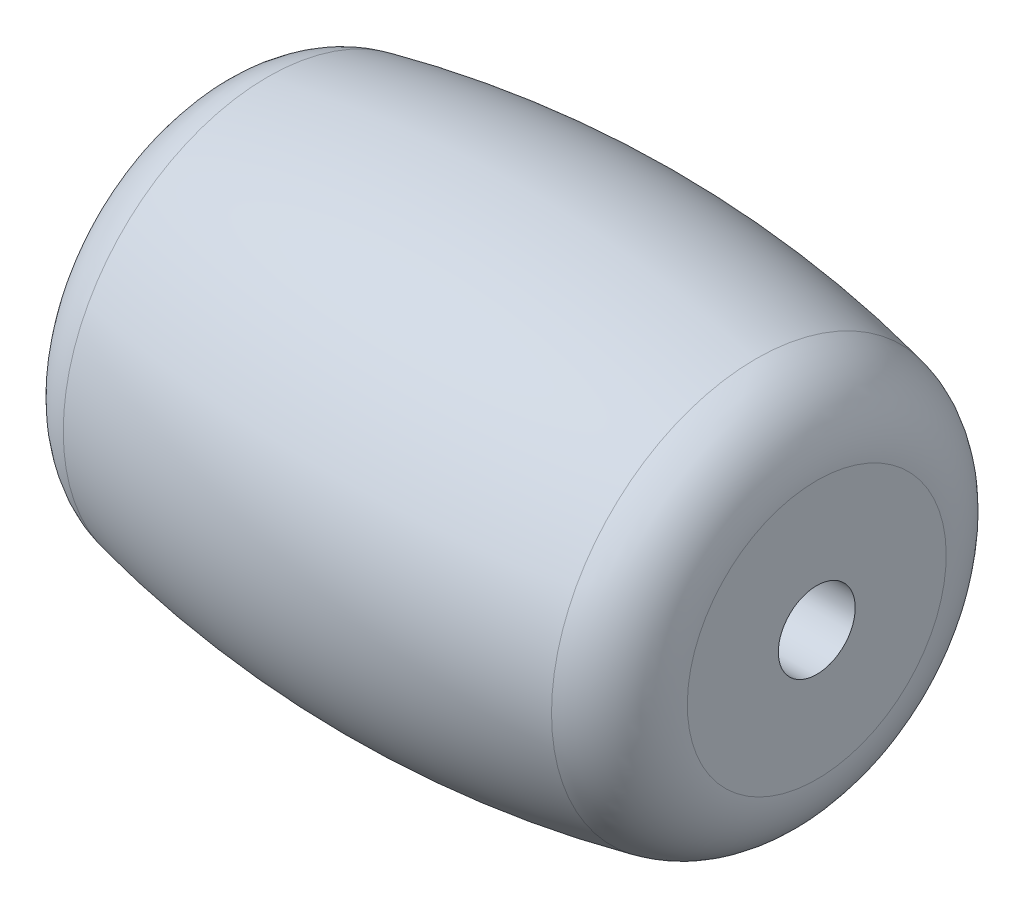
from build123d import *

# Parameters (mm, degrees)
RACCORDO1_R          = 2
RACCORDO2_R          = 2
FORO_0_2_0_2_1_D     = 2
FORO_0_2_0_2_1_DEPTH = 15.85


with BuildPart() as part:
    # Schizzo1 → Rivoluzione1 (revolve)
    with BuildSketch(Plane(origin=(0, 0, 0), x_dir=(-1, 0, 0), z_dir=(0, 0, -1))):
        with BuildLine():
            Line((-7.925, 4.934311379), (-7.925, 0))
            Line((-7.925, 0), (7.925, 0))
            Line((7.925, 0), (7.925, 4.934311379))
            ThreePointArc((7.925, 4.934311379), (0, 6), (-7.925, 4.934311379))
        make_face()
    revolve(axis=Axis((7.925, 0, 0), (-1, 0, 0)))

    # Raccordo1
    raccordo1_edges = [part.edges().sort_by_distance(p)[0] for p in [
        (7.925, -4.934311379, 0),
    ]]
    fillet(raccordo1_edges, radius=RACCORDO1_R)

    # Raccordo2
    raccordo2_edges = [part.edges().sort_by_distance(p)[0] for p in [
        (-7.925, -4.934311379, 0),
    ]]
    fillet(raccordo2_edges, radius=RACCORDO2_R)

    # Foro Ø0.2 (0.2)-1
    with Locations(Plane(origin=(7.925, 0, 0), x_dir=(0, 0, -1), z_dir=(1, 0, 0))):
        with Locations((0, 0)):
            Hole(FORO_0_2_0_2_1_D / 2, depth=FORO_0_2_0_2_1_DEPTH)


solid = part.part
